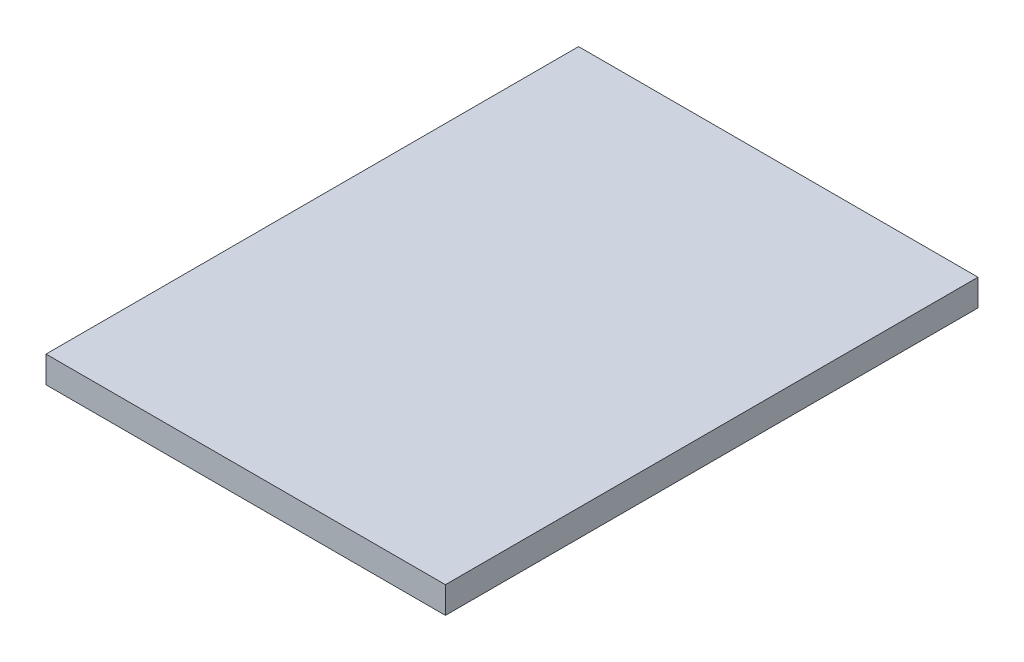
from build123d import *

# Parameters (mm, degrees)
SKETCH_1_W      = 150
SKETCH_1_H      = 200
EXTRUDE_1_DEPTH = 10


with BuildPart() as part:
    # Эскиз1 → Бобышка-Вытянуть1 (new body)
    with BuildSketch(Plane(origin=(0, 0, 0), x_dir=(1, 0, 0), z_dir=(0, 1, 0))):
        with Locations((75, 100)):
            Rectangle(SKETCH_1_W, SKETCH_1_H)
    extrude(amount=EXTRUDE_1_DEPTH)


solid = part.part
